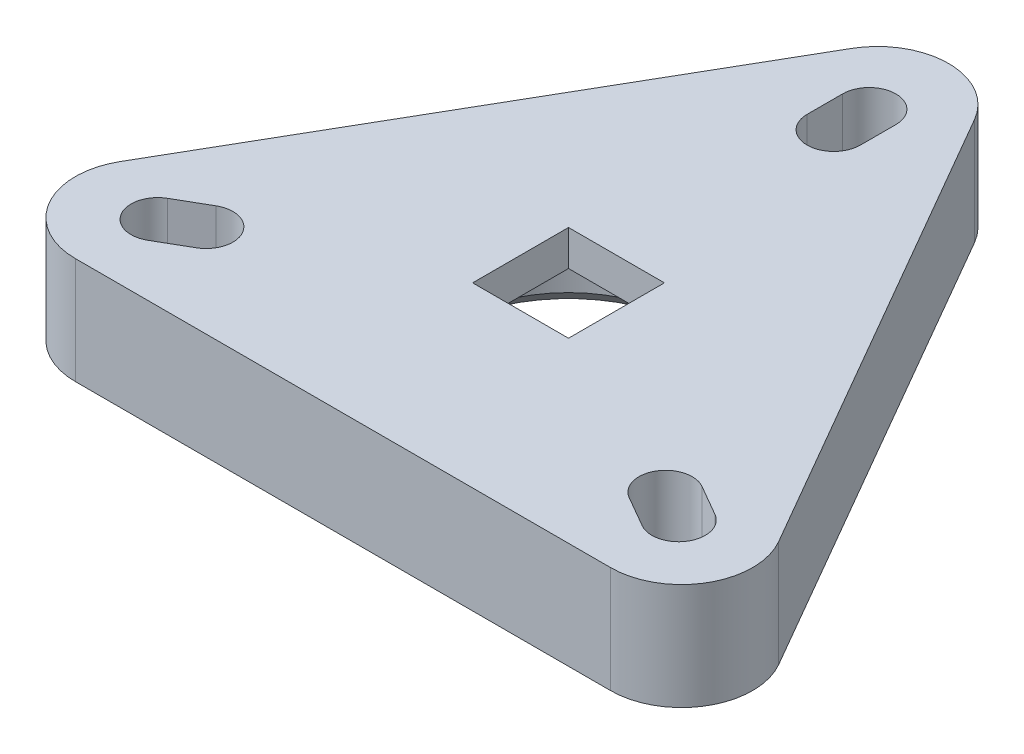
from build123d import *

# Parameters (mm, degrees)
SKETCH1_R           = 3.175
BOSS_EXTRUDE1_DEPTH = 7.62
SKETCH2_R           = 8.128
CUT_EXTRUDE1_DEPTH  = 5.08
SKETCH3_W           = 6.858
SKETCH3_H           = 6.858
CUT_EXTRUDE2_DEPTH  = 8.62
CHAMFER1_SIZE       = 1.27


with BuildPart() as part:
    # Sketch1 → Boss-Extrude1 (new body)
    with BuildSketch(Plane(origin=(0, 0, 0), x_dir=(1, 0, 0), z_dir=(0, 1, 0))):
        with BuildLine():
            ThreePointArc((-4.399409051, 24.642333042), (0, 27.182333042), (4.399409051, 24.642333042))
            Line((4.399409051, 24.642333042), (23.540590949, -8.511166521))
            ThreePointArc((23.540590949, -8.511166521), (23.540590949, -13.591166521), (19.141181898, -16.131166521))
            Line((19.141181898, -16.131166521), (-19.141181898, -16.131166521))
            ThreePointArc((-19.141181898, -16.131166521), (-23.540590949, -13.591166521), (-23.540590949, -8.511166521))
            Line((-23.540590949, -8.511166521), (-4.399409051, 24.642333042))
        make_face()
        Circle(SKETCH1_R, mode=Mode.SUBTRACT)
        with BuildLine():
            ThreePointArc((17.673352263, -12.403419212), (20.275630657, -11.706140818), (19.578352263, -9.103862424))
            Line((19.578352263, -9.103862424), (17.378647737, -7.833862424))
            ThreePointArc((17.378647737, -7.833862424), (14.776369343, -8.531140818), (15.473647737, -11.133419212))
            Line((15.473647737, -11.133419212), (17.673352263, -12.403419212))
        make_face(mode=Mode.SUBTRACT)
        with BuildLine():
            ThreePointArc((-15.473647737, -11.133419212), (-14.776369343, -8.531140818), (-17.378647737, -7.833862424))
            Line((-17.378647737, -7.833862424), (-19.578352263, -9.103862424))
            ThreePointArc((-19.578352263, -9.103862424), (-20.275630657, -11.706140818), (-17.673352263, -12.403419212))
            Line((-17.673352263, -12.403419212), (-15.473647737, -11.133419212))
        make_face(mode=Mode.SUBTRACT)
        with BuildLine():
            ThreePointArc((1.905, 21.507281636), (0, 23.412281636), (-1.905, 21.507281636))
            Line((-1.905, 21.507281636), (-1.905, 18.967281636))
            ThreePointArc((-1.905, 18.967281636), (0, 17.062281636), (1.905, 18.967281636))
            Line((1.905, 18.967281636), (1.905, 21.507281636))
        make_face(mode=Mode.SUBTRACT)
    extrude(amount=BOSS_EXTRUDE1_DEPTH)

    # Sketch2 → Cut-Extrude1 (cut)
    with BuildSketch(Plane.XZ):
        Circle(SKETCH2_R)
    extrude(amount=-CUT_EXTRUDE1_DEPTH, mode=Mode.SUBTRACT)

    # Sketch3 → Cut-Extrude2 (cut, through all)
    with BuildSketch(Plane(origin=(0, 0, 0), x_dir=(-1, 0, 0), z_dir=(0, -1, 0))):
        Rectangle(SKETCH3_W, SKETCH3_H)
    extrude(amount=-CUT_EXTRUDE2_DEPTH, mode=Mode.SUBTRACT)

    # Chamfer1
    chamfer1_edges = [part.edges().sort_by_distance(p)[0] for p in [
        (-8.128, 0, 0),
    ]]
    chamfer(chamfer1_edges, length=CHAMFER1_SIZE)


solid = part.part
